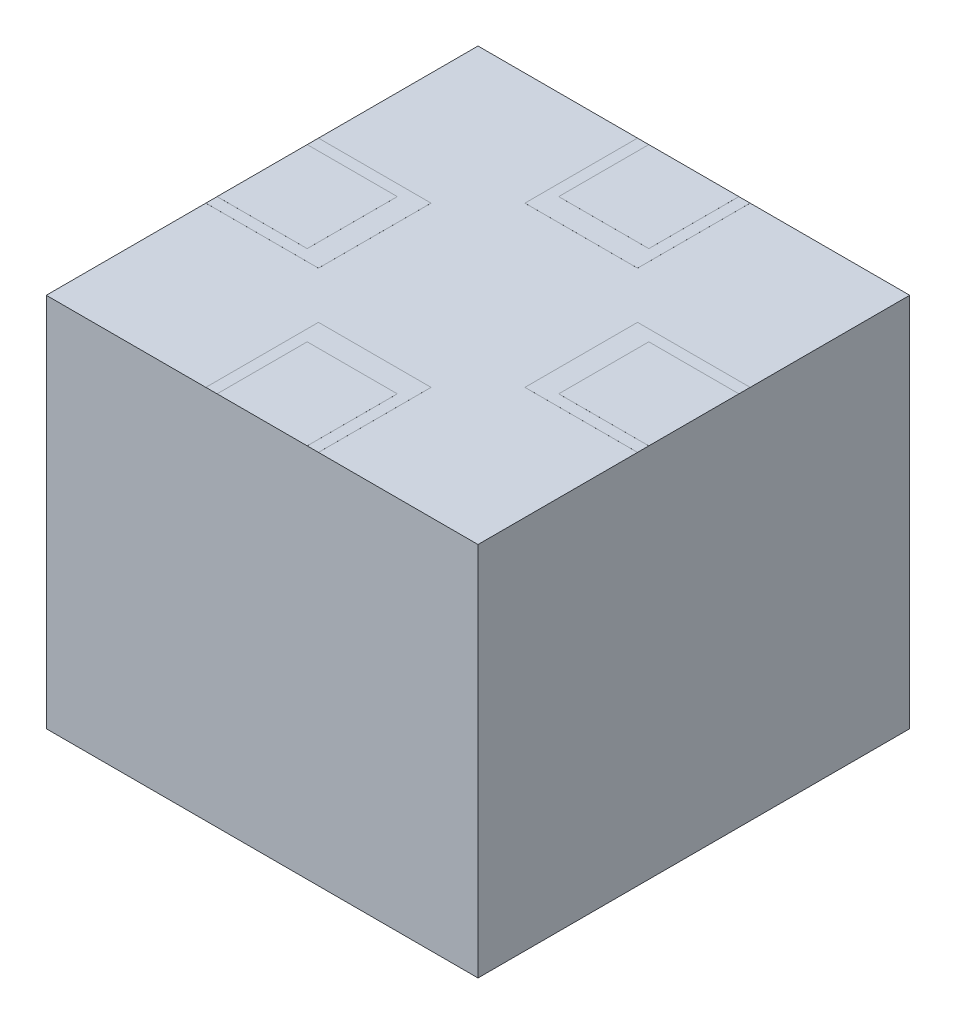
from build123d import *

# Parameters (mm, degrees)
SKETCH1_W           = 230
SKETCH1_H           = 230
BOSS_EXTRUDE1_DEPTH = 200
SKETCH3_W           = 60
SKETCH3_H           = 60
BOSS_EXTRUDE2_DEPTH = 0.01
SKETCH5_W           = 48
SKETCH5_H           = 48
BOSS_EXTRUDE3_DEPTH = 0.01


with BuildPart() as part:
    # Sketch1 → Boss-Extrude1 (new body)
    with BuildSketch(Plane(origin=(0, 0, 0), x_dir=(1, 0, 0), z_dir=(0, 1, 0))):
        Rectangle(SKETCH1_W, SKETCH1_H)
    extrude(amount=BOSS_EXTRUDE1_DEPTH)

    # Sketch3 → Boss-Extrude2 (add)
    with BuildSketch(Plane(origin=(0, 200, 0), x_dir=(1, 0, 0), z_dir=(0, 1, 0))):
        with Locations((85, 0)):
            Rectangle(SKETCH3_W, SKETCH3_H)
        with Locations((0, 85)):
            Rectangle(SKETCH3_W, SKETCH3_H)
        with Locations((0, -85)):
            Rectangle(SKETCH3_W, SKETCH3_H)
        with Locations((-85, 0)):
            Rectangle(SKETCH3_W, SKETCH3_H)
    extrude(amount=BOSS_EXTRUDE2_DEPTH)

    # Sketch5 → Boss-Extrude3 (add)
    with BuildSketch(Plane(origin=(0, 200.01, 0), x_dir=(1, 0, 0), z_dir=(0, 1, 0))):
        with Locations((0, 91)):
            Rectangle(SKETCH5_W, SKETCH5_H)
        with Locations((91, 0)):
            Rectangle(SKETCH5_W, SKETCH5_H)
        with Locations((0, -91)):
            Rectangle(SKETCH5_W, SKETCH5_H)
        with Locations((-91, 0)):
            Rectangle(SKETCH5_W, SKETCH5_H)
    extrude(amount=BOSS_EXTRUDE3_DEPTH)


solid = part.part
